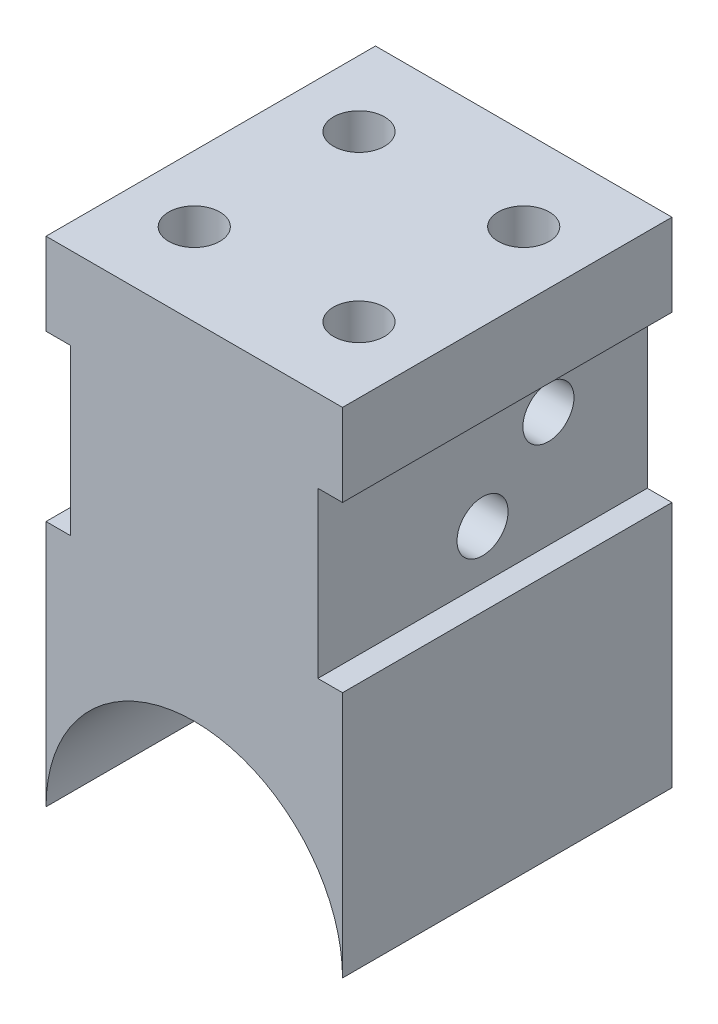
from build123d import *

# Parameters (mm, degrees)
EXTRUDE_1_DEPTH     = 20
SKETCH_2_W          = 20
SKETCH_2_H          = 10
CUT_EXTRUDE_1_DEPTH = 1.5
SKETCH_3_R          = 1.55
CUT_EXTRUDE_2_DEPTH = 15
SKETCH_4_R          = 1.55
CUT_EXTRUDE_5_DEPTH = 5
SKETCH_6_R          = 1.55
CUT_EXTRUDE_6_DEPTH = 10


with BuildPart() as part:
    # 草图1 → 凸台-拉伸1 (new body)
    with BuildSketch(Plane.XY):
        with BuildLine():
            Line((-9, 0), (-9, 30))
            Line((-9, 30), (9, 30))
            Line((9, 30), (9, 0))
            ThreePointArc((9, 0), (0, 9), (-9, 0))
        make_face()
    extrude(amount=EXTRUDE_1_DEPTH)

    # 草图2 → 切除-拉伸1 (cut)
    with BuildSketch(Plane.ZY.offset(9)):
        with Locations((10, 20)):
            Rectangle(SKETCH_2_W, SKETCH_2_H)
    cut_extrude_1 = extrude(amount=-CUT_EXTRUDE_1_DEPTH, mode=Mode.SUBTRACT)

    # 镜向1: 切除-拉伸1 across plane
    add(cut_extrude_1.mirror(Plane(origin=(0, 0, 0), x_dir=(0, 0, 1), z_dir=(1, 0, 0))), mode=Mode.SUBTRACT)

    # 草图3 → 切除-拉伸2 (cut)
    with BuildSketch(Plane(origin=(7.5, 0, 0), x_dir=(0, 0, -1), z_dir=(1, 0, 0))):
        with Locations((-6, 22)):
            Circle(SKETCH_3_R)
        with Locations((-10, 18)):
            Circle(SKETCH_3_R)
    extrude(amount=-CUT_EXTRUDE_2_DEPTH, mode=Mode.SUBTRACT)

    # 草图4 → 切除-拉伸5 (cut)
    with BuildSketch(Plane(origin=(0, 30, 0), x_dir=(1, 0, 0), z_dir=(0, 1, 0))):
        with Locations((-5, -5)):
            Circle(SKETCH_4_R)
        with Locations((5, -5)):
            Circle(SKETCH_4_R)
        with Locations((5, -15)):
            Circle(SKETCH_4_R)
        with Locations((-5, -15)):
            Circle(SKETCH_4_R)
    extrude(amount=-CUT_EXTRUDE_5_DEPTH, mode=Mode.SUBTRACT)

    # 草图6 → 切除-拉伸6 (cut)
    with BuildSketch(Plane(origin=(0, 30, 0), x_dir=(1, 0, 0), z_dir=(0, 1, 0))):
        with Locations((-5, -15)):
            Circle(SKETCH_6_R)
        with Locations((5, -15)):
            Circle(SKETCH_6_R)
    extrude(amount=-CUT_EXTRUDE_6_DEPTH, mode=Mode.SUBTRACT)


solid = part.part
